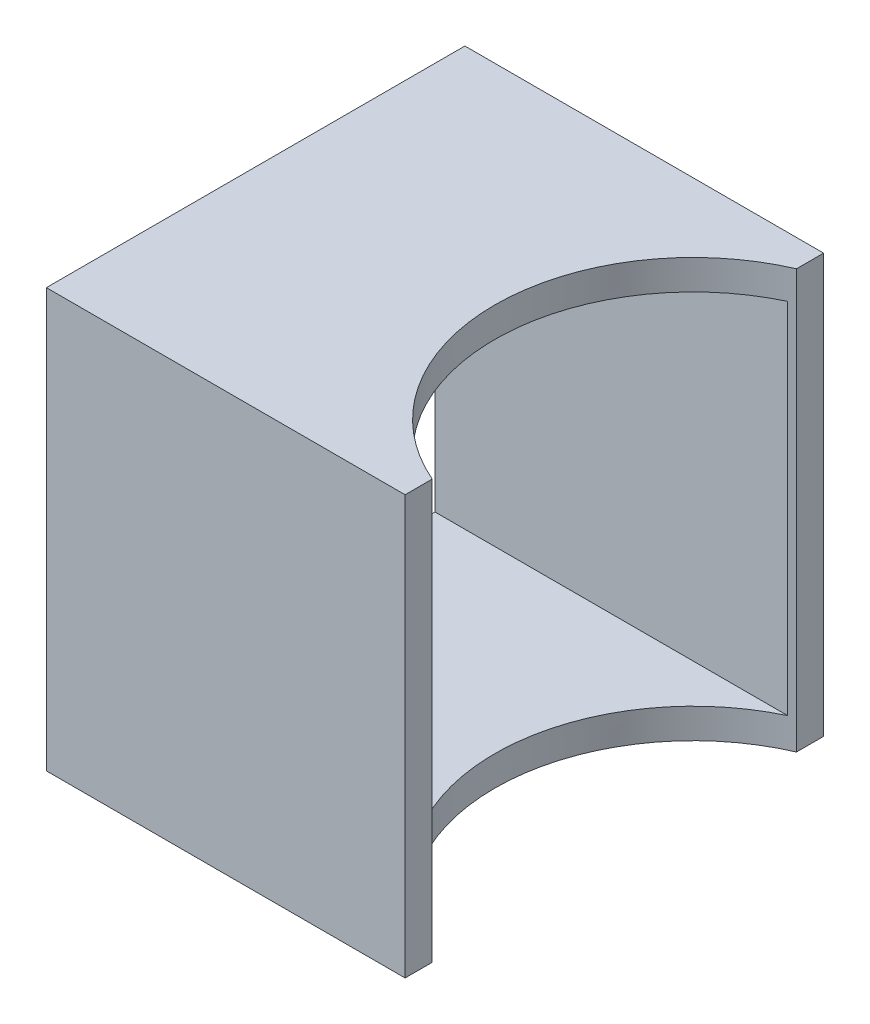
from build123d import *

# Parameters (mm, degrees)
BOSS_EXTRUDE1_DEPTH = 44.45
SKETCH2_W           = 38.1
SKETCH2_H           = 38.1
CUT_EXTRUDE1_DEPTH  = 39.1


with BuildPart() as part:
    # Sketch1 → Boss-Extrude1 (new body)
    with BuildSketch(Plane(origin=(0, 0, 0), x_dir=(1, 0, 0), z_dir=(0, 1, 0))):
        with BuildLine():
            Line((0, 22.225), (0, -22.225))
            Line((0, -22.225), (38.1, -22.225))
            Line((38.1, -22.225), (38.1, -19.344063689))
            ThreePointArc((38.1, -19.344063689), (25.4, 0), (38.1, 19.344063689))
            Line((38.1, 19.344063689), (38.1, 22.225))
            Line((38.1, 22.225), (0, 22.225))
        make_face()
    extrude(amount=BOSS_EXTRUDE1_DEPTH)

    # Sketch2 → Cut-Extrude1 (cut, through all)
    with BuildSketch(Plane.ZY):
        with Locations((0, 22.225)):
            Rectangle(SKETCH2_W, SKETCH2_H)
    extrude(amount=-CUT_EXTRUDE1_DEPTH, mode=Mode.SUBTRACT)


solid = part.part
